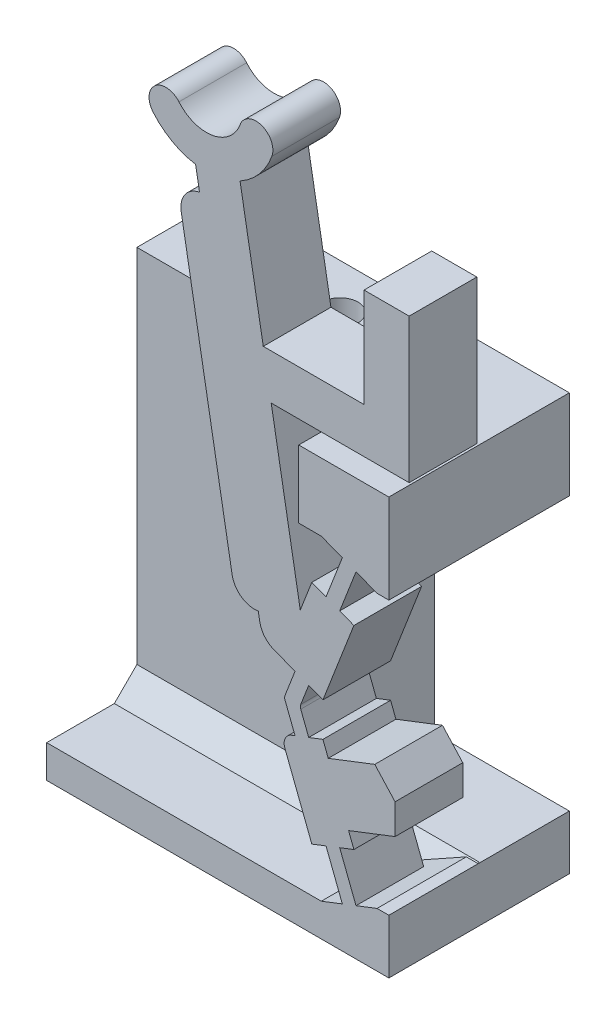
from build123d import *

# Parameters (mm, degrees)
BOSS_SWITCH_BODY_DEPTH            = 3
SKETCH1_W                         = 2.994375291
SKETCH1_H                         = 2.409101515
SKETCH1_W_2                       = 3.994375291
SKETCH1_H_2                       = 3.957767538
BOSS_FLANGE_WIDTH_DEPTH           = 5
BOSS_FLANGE_HEIGHT_REACH          = 36.354
SKETCH2_W                         = 4
SKETCH2_H                         = 3.957767538
SKETCH2_W_2                       = 8
SKETCH2_H_2                       = 1.451333978
SKETCH17_W                        = 15.1675
SKETCH17_H                        = 4
BOSS_FLANGE_SUPPORT_DEPTH         = 13.053634428
CUT_WALL_GAP_DEPTH                = 1
TAP_DRILL_FOR_M2X0_4_TAP1_D       = 1.6
M2_CLEARANCE_HOLE2_D              = 2.4
M2_CLEARANCE_HOLE2_DEPTH          = 13.462735941
CHAMFER_FLANGE_SUPPORT_3_SIZE     = 1
FILLET1_R                         = 1
FILLET2_R                         = 0.5
SKETCH28_W                        = 5.9675
SKETCH28_H                        = 12.095866891
CUT_PRINT_SUPPORT_CLEARANCE_DEPTH = 33.624103931


with BuildPart() as part:
    # Sketch-SwitchBossUp → Boss-Switch Body (new body)
    with BuildSketch(Plane.XY):
        with BuildLine():
            Line((-5.697895702, 26.949658376), (-5.524247524, 25.964850623))
            ThreePointArc((-5.524247524, 25.964850623), (-6.169751391, 25.553619307), (-6.3354071, 24.806394693))
            Line((-6.3354071, 24.806394693), (-4.07798079, 12.003893904))
            ThreePointArc((-4.07798079, 12.003893904), (-3.666749473, 11.358390037), (-2.919524859, 11.192734328))
            Line((-2.919524859, 11.192734328), (-2.755222696, 10.260930457))
            Line((-2.755222696, 10.260930457), (-1.920417042, 9.937339624))
            Line((-1.920417042, 9.937339624), (-1.291045382, 9.693379968))
            Line((-1.291045382, 9.693379968), (-1.735258621, 8.547390389))
            ThreePointArc((-1.735258621, 8.547390389), (-1.752158006, 8.457034961), (-1.735258621, 8.366679532))
            Line((-1.735258621, 8.366679532), (-1.291045382, 7.220689953))
            Line((-1.291045382, 7.220689953), (-1.920417042, 6.976730297))
            Line((-1.920417042, 6.976730297), (-0.547014535, 3.433600952))
            Line((-0.547014535, 3.433600952), (0.082357125, 3.677560608))
            Line((0.082357125, 3.677560608), (0.805200549, 1.81275569))
            Line((0.805200549, 1.81275569), (-0.12720191, 1.451333978))
            Line((-0.12720191, 1.451333978), (-0.12720191, 0))
            Line((-0.12720191, 0), (2.867173381, 0))
            Line((2.867173381, 0), (2.867173381, 2.409101515))
            Line((2.867173381, 2.409101515), (2.343664607, 2.409101515))
            Line((2.343664607, 2.409101515), (1.411262148, 2.047679803))
            Line((1.411262148, 2.047679803), (0.688418723, 3.912484721))
            Line((0.688418723, 3.912484721), (1.317790383, 4.156444377))
            Line((1.317790383, 4.156444377), (1.081123773, 4.767001302))
            Line((1.081123773, 4.767001302), (3.143260738, 5.566335394))
            Line((3.143260738, 5.566335394), (3.143260738, 6.901787438))
            Line((3.143260738, 6.901787438), (2.24307649, 7.888306327))
            Line((2.24307649, 7.888306327), (0.181054486, 7.089016797))
            Line((0.181054486, 7.089016797), (-0.055612124, 7.699573722))
            Line((-0.055612124, 7.699573722), (-0.684983784, 7.455614066))
            Line((-0.684983784, 7.455614066), (-1.038134762, 8.366679532))
            ThreePointArc((-1.038134762, 8.366679532), (-1.055034148, 8.457034961), (-1.038134762, 8.547390389))
            Line((-1.038134762, 8.547390389), (-0.684983784, 9.458455855))
            Line((-0.684983784, 9.458455855), (-0.055612124, 9.214496199))
            Line((-0.055612124, 9.214496199), (1.317790383, 12.757625544))
            Line((1.317790383, 12.757625544), (0.688418723, 13.0015852))
            Line((0.688418723, 13.0015852), (1.411262148, 14.866390118))
            Line((1.411262148, 14.866390118), (2.343664607, 14.504968406))
            Line((2.343664607, 14.504968406), (2.867173381, 14.504968406))
            Line((2.867173381, 14.504968406), (2.867173381, 18.462735944))
            Line((2.867173381, 18.462735944), (-0.111637615, 18.462735944))
            Line((-0.111637615, 18.462735944), (-1.12720191, 18.462735944))
            Line((-1.12720191, 18.462735944), (-1.12720191, 15.462735944))
            Line((-1.12720191, 15.462735944), (-0.12720191, 15.462735944))
            Line((-0.12720191, 15.462735944), (0.805200549, 15.101314231))
            Line((0.805200549, 15.101314231), (0.082357125, 13.236509313))
            Line((0.082357125, 13.236509313), (-0.547014535, 13.480468969))
            Line((-0.547014535, 13.480468969), (-1.059112089, 12.159350171))
            Line((-1.059112089, 12.159350171), (-2.346896051, 19.462735944))
            Line((-2.346896051, 19.462735944), (3.767173381, 19.462735944))
            Line((3.767173381, 19.462735944), (3.767173381, 25.857619356))
            Line((3.767173381, 25.857619356), (1.767173381, 25.857619356))
            Line((1.767173381, 25.857619356), (1.767173381, 21.462735944))
            Line((1.767173381, 21.462735944), (-2.699550012, 21.462735944))
            Line((-2.699550012, 21.462735944), (-3.728280196, 27.296954732))
            ThreePointArc((-3.728280196, 27.296954732), (-2.874356585, 27.992742953), (-2.319025652, 28.944012807))
            ThreePointArc((-2.319025652, 28.944012807), (-2.76728001, 29.905297381), (-3.728564583, 29.457043022))
            ThreePointArc((-3.728564583, 29.457043022), (-4.944660137, 28.436617692), (-6.436422172, 28.97957467))
            ThreePointArc((-6.436422172, 28.97957467), (-7.493046212, 29.072017295), (-7.585488837, 28.015393255))
            ThreePointArc((-7.585488837, 28.015393255), (-6.738295005, 27.311426358), (-5.697895702, 26.949658376))
        make_face()
    extrude(amount=BOSS_SWITCH_BODY_DEPTH)

    # Sketch1 → Boss-Flange Width (add)
    with BuildSketch(Plane(origin=(0, 0, 0), x_dir=(-1, 0, 0), z_dir=(0, 0, -1))):
        with Locations((-1.369985736, 1.204550758)):
            Rectangle(SKETCH1_W, SKETCH1_H)
        with Locations((-0.869985736, 16.483852175)):
            Rectangle(SKETCH1_W_2, SKETCH1_H_2)
    extrude(amount=BOSS_FLANGE_WIDTH_DEPTH)

    # Boss-Flange Height: up to this face of the body (flat: up to its plane)
    boss_flange_height_end = Plane(part.part.faces().sort_by_distance((-0.12720191, 1.077409098, -1.438016547))[0])
    # Sketch2 → Boss-Flange Height (add, up to the picked face)
    with BuildSketch(Plane(origin=(-12.300326619, 0, 0), x_dir=(0, 0, -1), z_dir=(1, 0, 0)), mode=Mode.PRIVATE) as boss_flange_height_sk1:
        with Locations((3, 16.483852175)):
            Rectangle(SKETCH2_W, SKETCH2_H)
    boss_flange_height_tool1 = split(extrude(boss_flange_height_sk1.sketch, amount=BOSS_FLANGE_HEIGHT_REACH, mode=Mode.PRIVATE), bisect_by=boss_flange_height_end, keep=Keep.BOTH, mode=Mode.PRIVATE)
    # Sketch2 → Boss-Flange Height (add, up to the picked face)
    with BuildSketch(Plane(origin=(-12.300326619, 0, 0), x_dir=(0, 0, -1), z_dir=(1, 0, 0)), mode=Mode.PRIVATE) as boss_flange_height_sk2:
        with Locations((1, 0.725666989)):
            Rectangle(SKETCH2_W_2, SKETCH2_H_2)
    boss_flange_height_tool2 = split(extrude(boss_flange_height_sk2.sketch, amount=BOSS_FLANGE_HEIGHT_REACH, mode=Mode.PRIVATE), bisect_by=boss_flange_height_end, keep=Keep.BOTH, mode=Mode.PRIVATE)
    add(boss_flange_height_tool1.solids().sort_by(Axis((-12.300327, 16.483852, -3), (1, 0, 0)))[0])
    add(boss_flange_height_tool2.solids().sort_by(Axis((-12.300327, 0.725667, -1), (1, 0, 0)))[0])

    # Sketch17 → Boss-Flange Support (add)
    with BuildSketch(Plane.XZ.offset(-1.451333978)):
        with Locations((-4.716576619, -3)):
            Rectangle(SKETCH17_W, SKETCH17_H)
    extrude(amount=-BOSS_FLANGE_SUPPORT_DEPTH)

    # Sketch27 → Cut-Wall Gap (cut)
    with BuildSketch(Plane.XY):
        Polygon((-0.12720191, 15.462735944), (2.343664607, 14.504968406), (-1.12720191, 14.504968406), (-1.12720191, 15.462735944), align=None)
        Polygon((2.343664607, 2.409101515), (-0.12720191, 2.409101515), (-0.12720191, 1.451333978), align=None)
    extrude(amount=-CUT_WALL_GAP_DEPTH, mode=Mode.SUBTRACT)

    # Tap Drill for M2x0.4 Tap1 (through all)
    with Locations(Plane(origin=(0, 0, 0), x_dir=(-1, 0, 0), z_dir=(0, -1, 0))):
        with Locations((9.300326619, 3), (5.300326619, 3)):
            Hole(TAP_DRILL_FOR_M2X0_4_TAP1_D / 2)

    # M2 Clearance Hole2
    with Locations(Plane.XZ):
        with Locations((-9.300326619, -3), (-5.300326619, -3)):
            Hole(M2_CLEARANCE_HOLE2_D / 2, depth=M2_CLEARANCE_HOLE2_DEPTH)

    # Chamfer-Flange Support 3
    chamfer_flange_support_3_edges = [part.edges().sort_by_distance(p)[0] for p in [
        (-6.213764264, 1.451333978, -1),
    ]]
    chamfer(chamfer_flange_support_3_edges, length=CHAMFER_FLANGE_SUPPORT_3_SIZE)

    # Fillet1
    fillet1_edges = [part.edges().sort_by_distance(p)[0] for p in [
        (-2.755222696, 10.260930457, 1.5),
    ]]
    fillet(fillet1_edges, radius=FILLET1_R)

    # Fillet2
    fillet2_edges = [part.edges().sort_by_distance(p)[0] for p in [
        (-1.920417042, 6.976730297, 1.5),
    ]]
    fillet(fillet2_edges, radius=FILLET2_R)

    # Sketch28 → Cut-Print Support Clearance (cut, through all)
    with BuildSketch(Plane.XY.offset(-1)):
        with Locations((-0.116576619, 8.457034961)):
            Rectangle(SKETCH28_W, SKETCH28_H)
    extrude(amount=-CUT_PRINT_SUPPORT_CLEARANCE_DEPTH, mode=Mode.SUBTRACT)


solid = part.part
